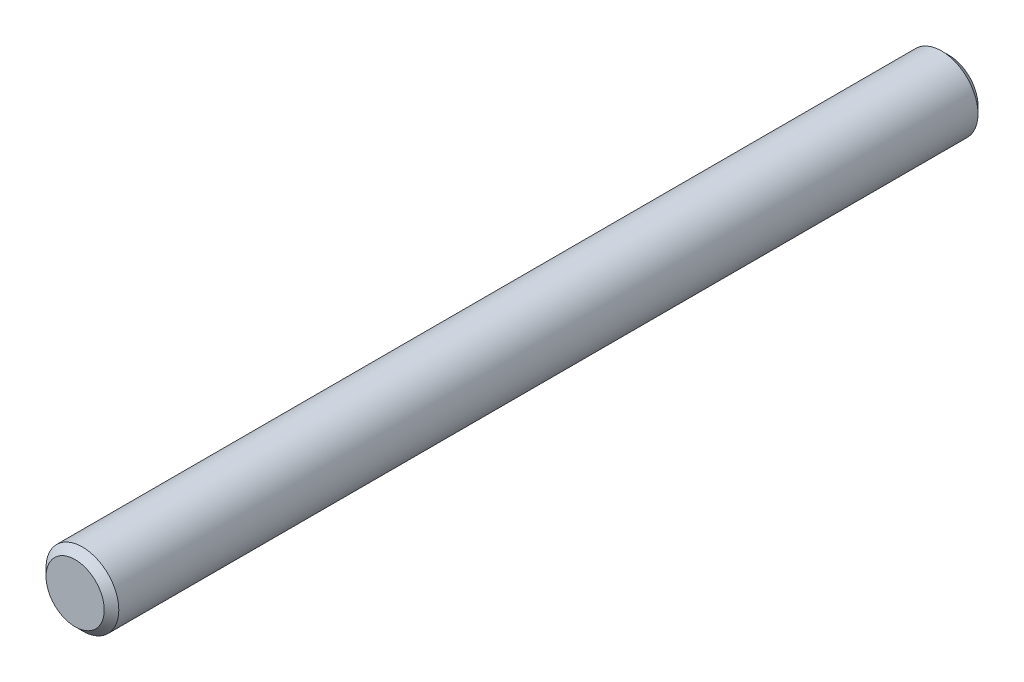
from build123d import *

# Parameters (mm, degrees)
SKETCH1_R           = 2.5
BOSS_EXTRUDE1_DEPTH = 60
CHAMFER1_SIZE       = 0.5


with BuildPart() as part:
    # Sketch1 → Boss-Extrude1 (new body)
    with BuildSketch(Plane.XY):
        Circle(SKETCH1_R)
    extrude(amount=BOSS_EXTRUDE1_DEPTH)

    # Chamfer1
    chamfer1_edges = [part.edges().sort_by_distance(p)[0] for p in [
        (-2.5, 0, 0),
        (-2.5, 0, 60),
    ]]
    chamfer(chamfer1_edges, length=CHAMFER1_SIZE)


solid = part.part
